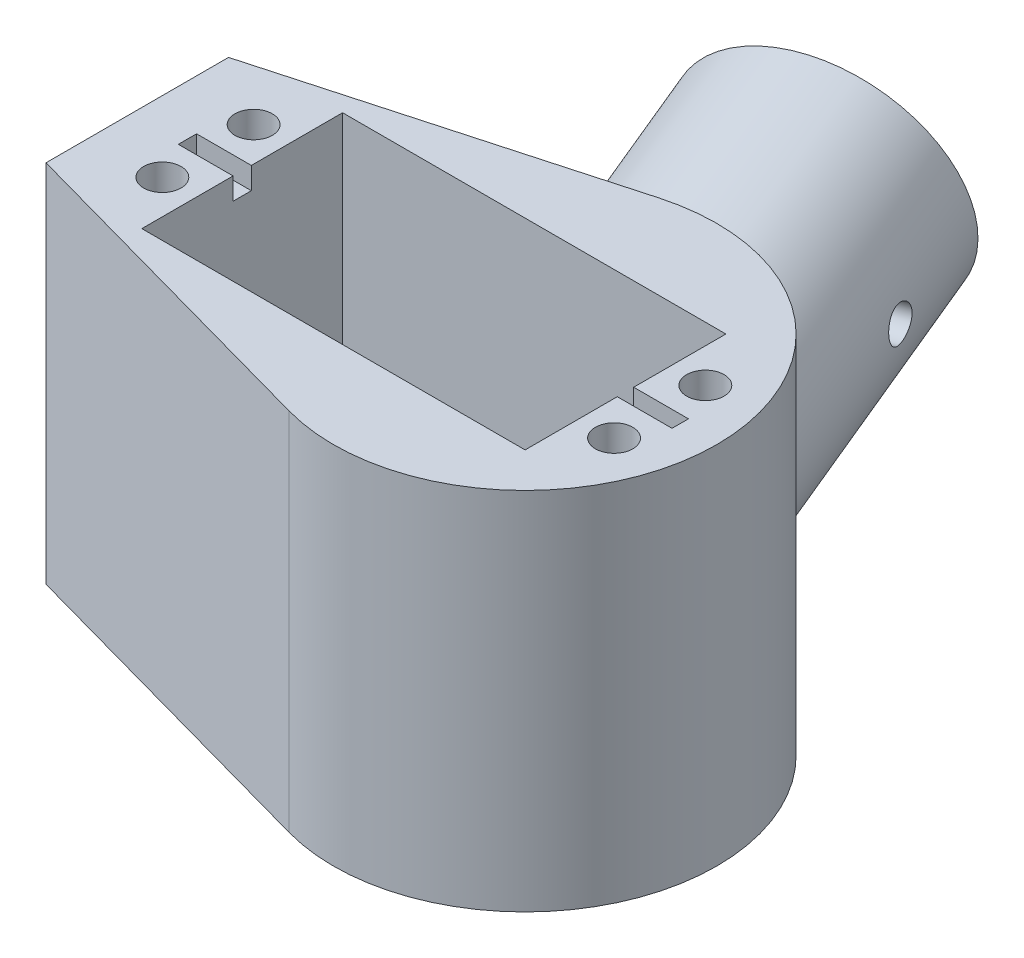
from build123d import *

# Parameters (mm, degrees)
SKETCH1_W           = 7.25
SKETCH1_H           = 20
SKETCH1_R           = 6
BOSS_EXTRUDE1_DEPTH = 40
SKETCH2_W           = 42
SKETCH2_H           = 22
CUT_EXTRUDE1_DEPTH  = 25
SKETCH3_R           = 2.05
CUT_EXTRUDE2_DEPTH  = 12
SKETCH4_R           = 9.55
CUT_EXTRUDE3_DEPTH  = 5
SKETCH5_R           = 9.55
CUT_EXTRUDE4_DEPTH  = 6
SKETCH7_W           = 6
SKETCH7_H           = 2
SKETCH7_H_2         = 1.8
CUT_EXTRUDE5_DEPTH  = 2.4
BOSS_EXTRUDE3_REACH = 79.413
SKETCH10_R          = 13.5
SKETCH10_R_2        = 10
BOSS_EXTRUDE4_REACH = 54.413
SKETCH11_R          = 10
SKETCH15_R          = 1.85
CUT_EXTRUDE8_DEPTH  = 13.5


with BuildPart() as part:
    # Sketch1 → Boss-Extrude1 (new body)
    with BuildSketch(Plane(origin=(0, 0, 0), x_dir=(1, 0, 0), z_dir=(0, 1, 0))):
        with BuildLine():
            Line((-30.25, -10), (-37.5, -10))
            Line((-37.5, -10), (-37.5, 10))
            Line((-37.5, 10), (-30.25, 10))
            Line((-30.25, 10), (-18.466185313, 10))
            ThreePointArc((-18.466185313, 10), (-13.083157843, 16.426532831), (-5.61521172, 20.235350191))
            Line((-5.61521172, 20.235350191), (-42.5, 10))
            Line((-42.5, 10), (-42.5, -10))
            Line((-42.5, -10), (-5.61521172, -20.235350191))
            ThreePointArc((-5.61521172, -20.235350191), (-13.083157843, -16.426532831), (-18.466185313, -10))
            Line((-18.466185313, -10), (-30.25, -10))
        make_face()
        with Locations((-33.875, 0)):
            Rectangle(SKETCH1_W, SKETCH1_H)
        with BuildLine():
            ThreePointArc((-18.466185313, 10), (-21, 0), (-18.466185313, -10))
            Line((-18.466185313, -10), (9.75, -10))
            Line((9.75, -10), (9.75, 10))
            Line((9.75, 10), (-18.466185313, 10))
        make_face()
        Circle(SKETCH1_R, mode=Mode.SUBTRACT)
        with BuildLine():
            Line((-30.25, 10), (-30.25, -10))
            Line((-30.25, -10), (-18.466185313, -10))
            ThreePointArc((-18.466185313, -10), (-21, 0), (-18.466185313, 10))
            Line((-18.466185313, 10), (-30.25, 10))
        make_face()
        with BuildLine():
            Line((9.75, -10), (-18.466185313, -10))
            ThreePointArc((-18.466185313, -10), (-13.083157843, -16.426532831), (-5.61521172, -20.235350191))
            ThreePointArc((-5.61521172, -20.235350191), (12.709849603, -16.717048874), (21, 0))
            ThreePointArc((21, 0), (12.709849603, 16.717048874), (-5.61521172, 20.235350191))
            ThreePointArc((-5.61521172, 20.235350191), (-13.083157843, 16.426532831), (-18.466185313, 10))
            Line((-18.466185313, 10), (9.75, 10))
            Line((9.75, 10), (17, 10))
            Line((17, 10), (17, -10))
            Line((17, -10), (9.75, -10))
        make_face()
        with Locations((13.375, 0)):
            Rectangle(SKETCH1_W, SKETCH1_H)
    extrude(amount=BOSS_EXTRUDE1_DEPTH)

    # Sketch2 → Cut-Extrude1 (cut)
    with BuildSketch(Plane(origin=(0, 40, 0), x_dir=(1, 0, 0), z_dir=(0, 1, 0))):
        with Locations((-10, 0)):
            Rectangle(SKETCH2_W, SKETCH2_H)
    extrude(amount=-CUT_EXTRUDE1_DEPTH, mode=Mode.SUBTRACT)

    # Sketch3 → Cut-Extrude2 (cut)
    with BuildSketch(Plane(origin=(0, 40, 0), x_dir=(1, 0, 0), z_dir=(0, 1, 0))):
        with Locations((14.75, 5)):
            Circle(SKETCH3_R)
        with Locations((14.75, -5)):
            Circle(SKETCH3_R)
        with Locations((-34.75, 5)):
            Circle(SKETCH3_R)
        with Locations((-34.75, -5)):
            Circle(SKETCH3_R)
    extrude(amount=-CUT_EXTRUDE2_DEPTH, mode=Mode.SUBTRACT)

    # Sketch4 → Cut-Extrude3 (cut)
    with BuildSketch(Plane(origin=(0, 15, 0), x_dir=(1, 0, 0), z_dir=(0, 1, 0))):
        Circle(SKETCH4_R)
    extrude(amount=-CUT_EXTRUDE3_DEPTH, mode=Mode.SUBTRACT)

    # Sketch5 → Cut-Extrude4 (cut)
    with BuildSketch(Plane.XZ):
        Circle(SKETCH5_R)
    extrude(amount=-CUT_EXTRUDE4_DEPTH, mode=Mode.SUBTRACT)

    # Sketch7 → Cut-Extrude5 (cut)
    with BuildSketch(Plane(origin=(0, 40, 0), x_dir=(1, 0, 0), z_dir=(0, 1, 0))):
        with Locations((-34, 0)):
            Rectangle(SKETCH7_W, SKETCH7_H)
        with Locations((14, 0)):
            Rectangle(SKETCH7_W, SKETCH7_H_2)
    extrude(amount=-CUT_EXTRUDE5_DEPTH, mode=Mode.SUBTRACT)

    # Sketch10 → Boss-Extrude3 (add, up to next)
    with BuildSketch(Plane(origin=(-14.44792881, 9.795327955, -48.752531942), x_dir=(-0.168490085, 0.955554754, 0.241921896), z_dir=(0.279007999, -0.189160321, 0.941473796)), mode=Mode.PRIVATE) as boss_extrude3_sk1:
        with Locations((15.161828301, -3.96392858)):
            Circle(SKETCH10_R)
        with Locations((15.161828301, -3.96392858)):
            Circle(SKETCH10_R_2, mode=Mode.SUBTRACT)
    boss_extrude3_tool1 = extrude(boss_extrude3_sk1.sketch, amount=BOSS_EXTRUDE3_REACH, mode=Mode.PRIVATE) - part.part
    add(boss_extrude3_tool1.solids().sort_by_distance((-11.044801, 12.644515, -49.1886))[0])

    # Sketch11 → Boss-Extrude4 (add, up to next)
    with BuildSketch(Plane(origin=(-7.472728833, 5.066319927, -25.215687031), x_dir=(-0.960288778, -0.054959762, 0.273541383), z_dir=(-0.279007999, 0.189160321, -0.941473796)), mode=Mode.PRIVATE) as boss_extrude4_sk1:
        with Locations((-1.242176115, 15.622124238)):
            Circle(SKETCH11_R)
    boss_extrude4_tool1 = extrude(boss_extrude4_sk1.sketch, amount=-BOSS_EXTRUDE4_REACH, mode=Mode.PRIVATE) - part.part
    add(boss_extrude4_tool1.solids().sort_by_distance((-6.279881, 20.450629, -22.478185))[0])

    # Sketch15 → Cut-Extrude8 (cut, symmetric)
    with BuildSketch(Plane(origin=(1.192847783, 0.068269704, -0.339786572), x_dir=(-0.279007999, 0.189160321, -0.941473796), z_dir=(-0.960288778, -0.054959762, 0.273541383))):
        with Locations((39.283206422, -15.622124238)):
            Circle(SKETCH15_R)
    extrude(amount=CUT_EXTRUDE8_DEPTH, both=True, mode=Mode.SUBTRACT)


solid = part.part
